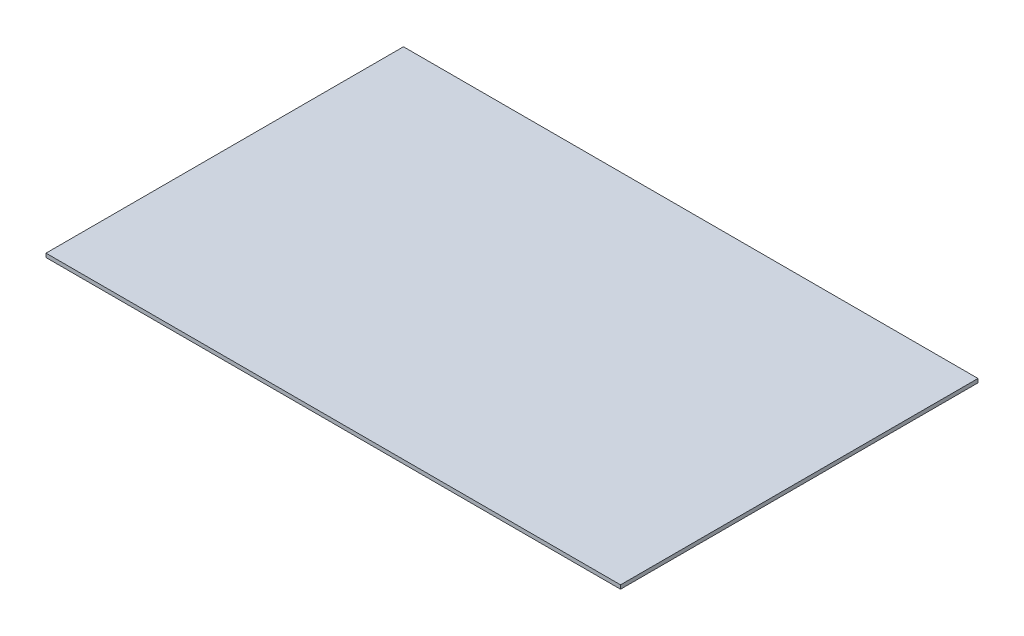
from build123d import *

# Parameters (mm, degrees)
SKETCH1_W           = 450
SKETCH1_H           = 280
BOSS_EXTRUDE1_DEPTH = 3


with BuildPart() as part:
    # Sketch1 → Boss-Extrude1 (new body)
    with BuildSketch(Plane(origin=(0, 0, 0), x_dir=(1, 0, 0), z_dir=(0, 1, 0))):
        Rectangle(SKETCH1_W, SKETCH1_H)
    extrude(amount=BOSS_EXTRUDE1_DEPTH)


solid = part.part
